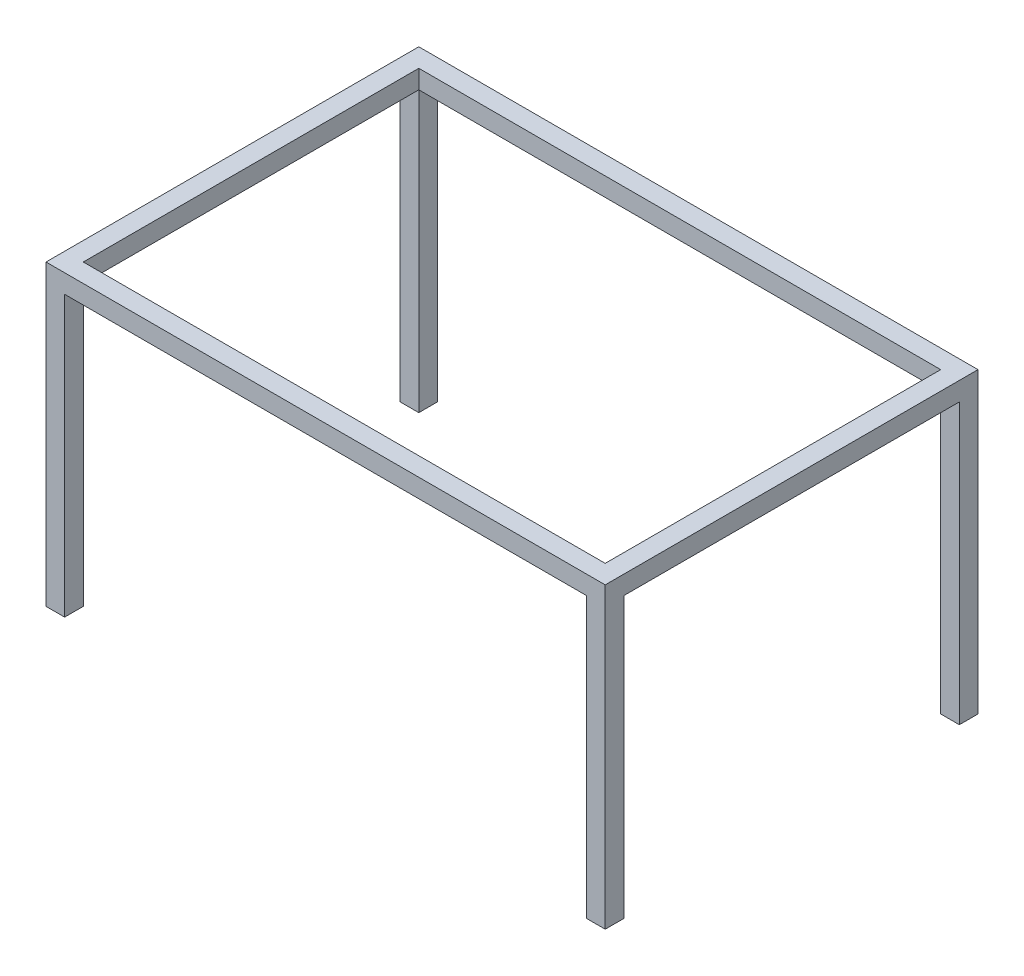
from build123d import *

# Parameters (mm, degrees)
CROQUIS1_W              = 3000
CROQUIS1_H              = 2000
CROQUIS1_W_2            = 2800
CROQUIS1_H_2            = 1800
SALIENTE_EXTRUIR1_DEPTH = 100
CROQUIS2_W              = 100
CROQUIS2_H              = 100
SALIENTE_EXTRUIR2_DEPTH = 1500


with BuildPart() as part:
    # Croquis1 → Saliente-Extruir1 (new body)
    with BuildSketch(Plane(origin=(0, 0, 0), x_dir=(1, 0, 0), z_dir=(0, 1, 0))):
        Rectangle(CROQUIS1_W, CROQUIS1_H)
        Rectangle(CROQUIS1_W_2, CROQUIS1_H_2, mode=Mode.SUBTRACT)
    extrude(amount=SALIENTE_EXTRUIR1_DEPTH)

    # Croquis2 → Saliente-Extruir2 (add)
    with BuildSketch(Plane.XZ):
        with Locations((-1450, 950)):
            Rectangle(CROQUIS2_W, CROQUIS2_H)
        with Locations((-1450, -950)):
            Rectangle(CROQUIS2_W, CROQUIS2_H)
        with Locations((1450, -950)):
            Rectangle(CROQUIS2_W, CROQUIS2_H)
        with Locations((1450, 950)):
            Rectangle(CROQUIS2_W, CROQUIS2_H)
    extrude(amount=SALIENTE_EXTRUIR2_DEPTH)


solid = part.part
